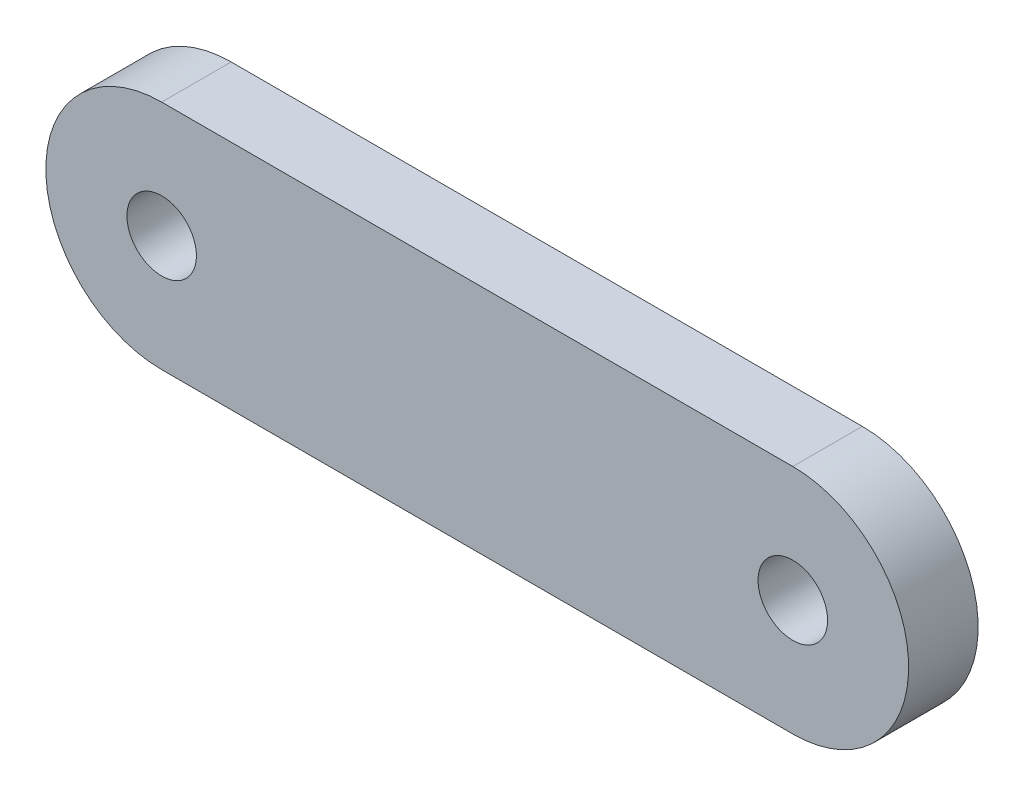
from build123d import *

# Parameters (mm, degrees)
SKETCH_1_R      = 0.75
EXTRUDE_1_DEPTH = 0.75


with BuildPart() as part:
    # 草圖1 → 填料-伸長1 (new body, symmetric)
    with BuildSketch(Plane.XY):
        with BuildLine():
            Line((-6.81, 2.5), (6.81, 2.5))
            ThreePointArc((6.81, 2.5), (9.31, 0), (6.81, -2.5))
            Line((6.81, -2.5), (-6.81, -2.5))
            ThreePointArc((-6.81, -2.5), (-9.31, 0), (-6.81, 2.5))
        make_face()
        with Locations((-6.81, 0)):
            Circle(SKETCH_1_R, mode=Mode.SUBTRACT)
        with Locations((6.81, 0)):
            Circle(SKETCH_1_R, mode=Mode.SUBTRACT)
    extrude(amount=EXTRUDE_1_DEPTH, both=True)


solid = part.part
